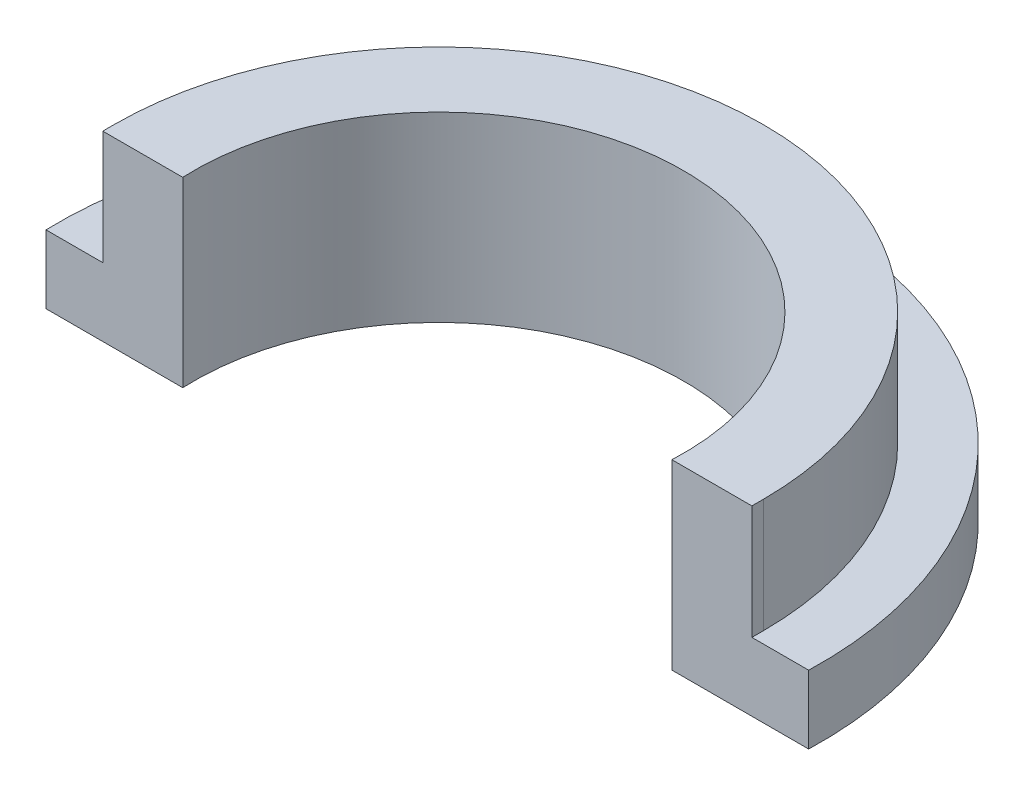
from build123d import *
from build123d.topology import SkipClean

# Parameters (mm, degrees)
BOSS_EXTRUDE2_DEPTH = 2
BOSS_EXTRUDE3_DEPTH = 4
BOSS_EXTRUDE4_DEPTH = 0.4
BOSS_EXTRUDE6_DEPTH = 0.4


with BuildPart() as part:
    # Sketch4 → Boss-Extrude2 (new body)
    with BuildSketch(Plane(origin=(0, 0, 0), x_dir=(1, 0, 0), z_dir=(0, 1, 0))):
        with BuildLine():
            Line((-13.39402852, -0.4), (-8.590692638, -0.4))
            ThreePointArc((-8.590692638, -0.4), (0, 8.6), (8.590692638, -0.4))
            Line((8.590692638, -0.4), (13.39402852, -0.4))
            ThreePointArc((13.39402852, -0.4), (0, 13.4), (-13.39402852, -0.4))
        make_face()
        with BuildLine():
            Line((9, 0), (13, 0))
            ThreePointArc((13, 0), (0, 13), (-13, 0))
            Line((-13, 0), (-9, 0))
            ThreePointArc((-9, 0), (0, 9), (9, 0))
        make_face(mode=Mode.SUBTRACT)
    extrude(amount=BOSS_EXTRUDE2_DEPTH)

    # Sketch5 → Boss-Extrude3 (add)
    with BuildSketch(Plane(origin=(0, 2, 0), x_dir=(1, 0, 0), z_dir=(0, 1, 0))):
        with BuildLine():
            Line((-11.4, 0), (-11.4, -0.4))
            Line((-11.4, -0.4), (-8.590692638, -0.4))
            ThreePointArc((-8.590692638, -0.4), (0, 8.6), (8.590692638, -0.4))
            Line((8.590692638, -0.4), (11.4, -0.4))
            Line((11.4, -0.4), (11.4, 0))
            ThreePointArc((11.4, 0), (0, 11.4), (-11.4, 0))
        make_face()
        with BuildLine():
            Line((-11, 0), (-9, 0))
            ThreePointArc((-9, 0), (0, 9), (9, 0))
            Line((9, 0), (11, 0))
            ThreePointArc((11, 0), (0, 11), (-11, 0))
        make_face(mode=Mode.SUBTRACT)
    extrude(amount=BOSS_EXTRUDE3_DEPTH)

    # Sketch6 → Boss-Extrude4 (add)
    with BuildSketch(Plane(origin=(0, 2, 0), x_dir=(1, 0, 0), z_dir=(0, 1, 0))):
        with BuildLine():
            Line((-13.39402852, -0.4), (-11.4, -0.4))
            Line((-11.4, -0.4), (-11.4, 0))
            ThreePointArc((-11.4, 0), (0, 11.4), (11.4, 0))
            Line((11.4, 0), (11.4, -0.4))
            Line((11.4, -0.4), (13.39402852, -0.4))
            ThreePointArc((13.39402852, -0.4), (0, 13.4), (-13.39402852, -0.4))
        make_face()
    extrude(amount=BOSS_EXTRUDE4_DEPTH)

    # Sketch8 → Boss-Extrude6 (add)
    with SkipClean():  # the faces are left unmerged after this step: merging them gives an invalid solid
        with BuildSketch(Plane(origin=(0, 6, 0), x_dir=(1, 0, 0), z_dir=(0, 1, 0))):
            with BuildLine():
                Line((11.4, 0), (11.4, -0.4))
                Line((11.4, -0.4), (8.590692638, -0.4))
                ThreePointArc((8.590692638, -0.4), (0, 8.6), (-8.590692638, -0.4))
                Line((-8.590692638, -0.4), (-11.4, -0.4))
                Line((-11.4, -0.4), (-11.4, 0))
                ThreePointArc((-11.4, 0), (0, 11.4), (11.4, 0))
            make_face()
        extrude(amount=BOSS_EXTRUDE6_DEPTH)


solid = part.part
